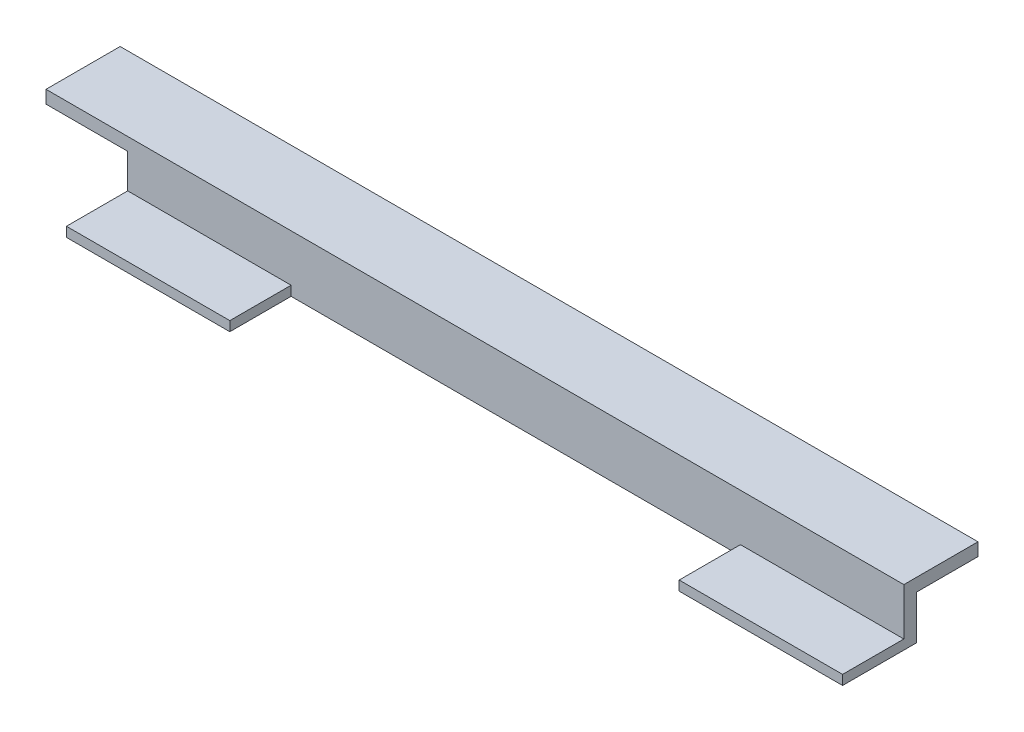
from build123d import *

# Parameters (mm, degrees)
SKETCH1_W           = 2
SKETCH1_H           = 1.5
SKETCH1_W_2         = 9.525
BOSS_EXTRUDE1_DEPTH = 120.65
SKETCH2_W           = 69.85
SKETCH2_H           = 9.525
CUT_EXTRUDE1_DEPTH  = 9.825996
SKETCH3_W           = 11.525
SKETCH3_H           = 2
BOSS_EXTRUDE3_DEPTH = 12.7


with BuildPart() as part:
    # Sketch1 → Boss-Extrude1 (new body)
    with BuildSketch(Plane(origin=(0, 0, 0), x_dir=(0, 0, -1), z_dir=(1, 0, 0))):
        Polygon((-2, 8.825996), (-2, 1.5), (0, 1.5), (0, 6.825996), (9.525, 6.825996), (9.525, 8.825996), align=None)
        with Locations((-1, 0.75)):
            Rectangle(SKETCH1_W, SKETCH1_H)
        with Locations((-6.7625, 0.75)):
            Rectangle(SKETCH1_W_2, SKETCH1_H)
    extrude(amount=BOSS_EXTRUDE1_DEPTH)

    # Sketch2 → Cut-Extrude1 (cut, through all)
    with BuildSketch(Plane.XZ):
        with Locations((60.325, 6.7625)):
            Rectangle(SKETCH2_W, SKETCH2_H)
    extrude(amount=-CUT_EXTRUDE1_DEPTH, mode=Mode.SUBTRACT)

    # Sketch3 → Boss-Extrude3 (add)
    with BuildSketch(Plane.ZY):
        with Locations((-3.7625, 7.825996)):
            Rectangle(SKETCH3_W, SKETCH3_H)
    extrude(amount=BOSS_EXTRUDE3_DEPTH)


solid = part.part
